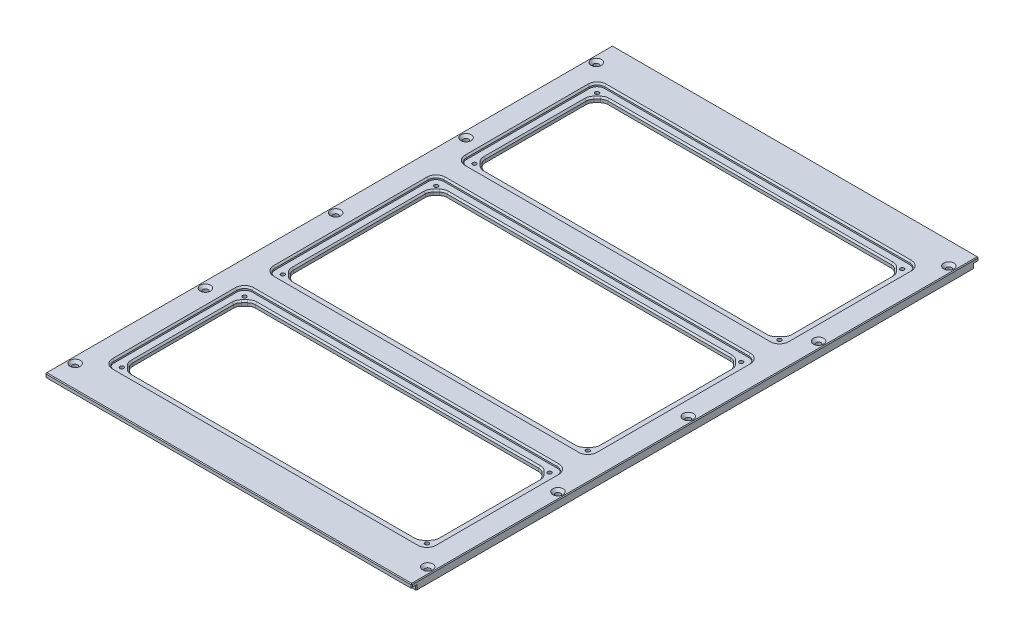
from build123d import *

# Parameters (mm, degrees)
SKETCH1_W                                            = 239
SKETCH1_H                                            = 370
BOSS_EXTRUDE1_DEPTH                                  = 5
CSK_FOR_M3_HEX_SOCKET_COUNTERSUNK_CAP_SC_D           = 3.4
CSK_FOR_M3_HEX_SOCKET_COUNTERSUNK_CAP_SC_CSINK_D     = 6.72
CSK_FOR_M3_HEX_SOCKET_COUNTERSUNK_CAP_SC_CSINK_ANGLE = 90
SKETCH4_W                                            = 209
SKETCH4_H                                            = 90
SKETCH4_H_2                                          = 110
CUT_EXTRUDE1_DEPTH                                   = 2
SKETCH5_W                                            = 199
SKETCH5_H                                            = 100
SKETCH5_H_2                                          = 80
CUT_EXTRUDE2_DEPTH                                   = 4
CHAMFER1_SIZE                                        = 5
FILLET1_R                                            = 5
CUT_EXTRUDE3_DEPTH                                   = 4
M3_TAPPED_HOLE1_AT_2_COUNT                           = 2
M3_TAPPED_HOLE1_AT_2_PITCH                           = 80
M3_TAPPED_HOLE1_AT_3_COUNT                           = 2
M3_TAPPED_HOLE1_AT_3_PITCH                           = 25
M3_TAPPED_HOLE1_AT_4_COUNT                           = 2
M3_TAPPED_HOLE1_AT_4_PITCH                           = 125
M3_TAPPED_HOLE1_AT_5_COUNT                           = 2
M3_TAPPED_HOLE1_AT_5_PITCH                           = 150
M3_TAPPED_HOLE1_AT_6_COUNT                           = 2
M3_TAPPED_HOLE1_AT_6_PITCH                           = 230
CHAMFER2_SIZE                                        = 1
SKETCH12_W                                           = 239
SKETCH12_H                                           = 3
CUT_EXTRUDE7_DEPTH                                   = 2.5
CHAMFER3_SIZE                                        = 0.5


with BuildPart() as part:
    # Sketch1 → Boss-Extrude1 (new body)
    with BuildSketch(Plane(origin=(0, 0, 0), x_dir=(1, 0, 0), z_dir=(0, 1, 0))):
        with Locations((-119.5, 185)):
            Rectangle(SKETCH1_W, SKETCH1_H)
    extrude(amount=BOSS_EXTRUDE1_DEPTH)

    # CSK for M3 Hex Socket Countersunk Cap Screw1 (through all)
    with Locations(Plane(origin=(0, 5, 0), x_dir=(1, 0, 0), z_dir=(0, 1, 0))):
        with Locations((-4.5, 15), (-4.5, 100), (-4.5, 185), (-4.5, 270), (-4.5, 355)):
            csk_for_m3_hex_socket_countersunk_cap_sc = CounterSinkHole(CSK_FOR_M3_HEX_SOCKET_COUNTERSUNK_CAP_SC_D / 2, CSK_FOR_M3_HEX_SOCKET_COUNTERSUNK_CAP_SC_CSINK_D / 2, counter_sink_angle=CSK_FOR_M3_HEX_SOCKET_COUNTERSUNK_CAP_SC_CSINK_ANGLE)

    # Sketch4 → Cut-Extrude1 (cut)
    with BuildSketch(Plane(origin=(0, 5, 0), x_dir=(1, 0, 0), z_dir=(0, 1, 0))):
        with Locations((-119.5, 300)):
            Rectangle(SKETCH4_W, SKETCH4_H)
        with Locations((-119.5, 185)):
            Rectangle(SKETCH4_W, SKETCH4_H_2)
        with Locations((-119.5, 70)):
            Rectangle(SKETCH4_W, SKETCH4_H)
    extrude(amount=-CUT_EXTRUDE1_DEPTH, mode=Mode.SUBTRACT)

    # Sketch5 → Cut-Extrude2 (cut, through all)
    with BuildSketch(Plane(origin=(0, 3, 0), x_dir=(1, 0, 0), z_dir=(0, 1, 0))):
        with Locations((-119.5, 185)):
            Rectangle(SKETCH5_W, SKETCH5_H)
        with Locations((-119.5, 70)):
            Rectangle(SKETCH5_W, SKETCH5_H_2)
        with Locations((-119.5, 300)):
            Rectangle(SKETCH5_W, SKETCH5_H_2)
    extrude(amount=-CUT_EXTRUDE2_DEPTH, mode=Mode.SUBTRACT)

    # Chamfer1
    chamfer1_edges = [part.edges().sort_by_distance(p)[0] for p in [
        (-219, 1.5, -30),
        (-219, 1.5, -110),
        (-20, 1.5, -260),
        (-219, 1.5, -260),
        (-219, 1.5, -340),
        (-20, 1.5, -340),
        (-20, 1.5, -235),
        (-20, 1.5, -135),
        (-219, 1.5, -135),
        (-219, 1.5, -235),
        (-20, 1.5, -110),
        (-20, 1.5, -30),
    ]]
    chamfer(chamfer1_edges, length=CHAMFER1_SIZE)

    # Fillet1
    fillet1_edges = [part.edges().sort_by_distance(p)[0] for p in [
        (-20, 1.5, -105),
        (-20, 1.5, -35),
        (-214, 1.5, -30),
        (-25, 1.5, -30),
        (-214, 1.5, -110),
        (-25, 1.5, -110),
        (-219, 1.5, -35),
        (-219, 1.5, -105),
        (-25, 1.5, -135),
        (-214, 1.5, -135),
        (-219, 1.5, -230),
        (-219, 1.5, -140),
        (-20, 1.5, -230),
        (-20, 1.5, -140),
        (-214, 1.5, -235),
        (-25, 1.5, -235),
        (-25, 1.5, -260),
        (-214, 1.5, -260),
        (-219, 1.5, -335),
        (-219, 1.5, -265),
        (-20, 1.5, -335),
        (-20, 1.5, -265),
        (-214, 1.5, -340),
        (-25, 1.5, -340),
        (-15, 4, -240),
        (-15, 4, -130),
        (-224, 4, -130),
        (-224, 4, -240),
        (-224, 4, -25),
        (-224, 4, -115),
        (-15, 4, -115),
        (-15, 4, -25),
        (-15, 4, -255),
        (-224, 4, -255),
        (-224, 4, -345),
        (-15, 4, -345),
    ]]
    fillet(fillet1_edges, radius=FILLET1_R)

    # Sketch6 → Cut-Extrude3 (cut)
    with BuildSketch(Plane.XZ):
        with BuildLine():
            Line((-224, -115.5), (-169, -115.5))
            ThreePointArc((-169, -115.5), (-162, -122.5), (-169, -129.5))
            Line((-169, -129.5), (-224, -129.5))
            ThreePointArc((-224, -129.5), (-231, -122.5), (-224, -115.5))
        make_face()
        with BuildLine():
            Line((-147, -115.5), (-92, -115.5))
            ThreePointArc((-92, -115.5), (-85, -122.5), (-92, -129.5))
            Line((-92, -129.5), (-147, -129.5))
            ThreePointArc((-147, -129.5), (-154, -122.5), (-147, -115.5))
        make_face()
        with BuildLine():
            Line((-70, -115.5), (-15, -115.5))
            ThreePointArc((-15, -115.5), (-8, -122.5), (-15, -129.5))
            Line((-15, -129.5), (-70, -129.5))
            ThreePointArc((-70, -129.5), (-77, -122.5), (-70, -115.5))
        make_face()
        with BuildLine():
            Line((-70, -254.5), (-15, -254.5))
            ThreePointArc((-15, -254.5), (-8, -247.5), (-15, -240.5))
            Line((-15, -240.5), (-70, -240.5))
            ThreePointArc((-70, -240.5), (-77, -247.5), (-70, -254.5))
        make_face()
        with BuildLine():
            Line((-147, -254.5), (-92, -254.5))
            ThreePointArc((-92, -254.5), (-85, -247.5), (-92, -240.5))
            Line((-92, -240.5), (-147, -240.5))
            ThreePointArc((-147, -240.5), (-154, -247.5), (-147, -254.5))
        make_face()
        with BuildLine():
            Line((-224, -254.5), (-169, -254.5))
            ThreePointArc((-169, -254.5), (-162, -247.5), (-169, -240.5))
            Line((-169, -240.5), (-224, -240.5))
            ThreePointArc((-224, -240.5), (-231, -247.5), (-224, -254.5))
        make_face()
        with BuildLine():
            Line((-196.798970952, -9.803274452), (-160.068481328, -23.803274452))
            ThreePointArc((-160.068481328, -23.803274452), (-157.297860755, -23.470368797), (-156, -21))
            Line((-156, -21), (-156, -7))
            ThreePointArc((-156, -7), (-156.878679656, -4.878679656), (-159, -4))
            Line((-159, -4), (-195.730489624, -4))
            ThreePointArc((-195.730489624, -4), (-198.680898355, -6.456779674), (-196.798970952, -9.803274452))
        make_face()
        with BuildLine():
            Line((-183.201029048, -18.196725548), (-219.931518672, -4.196725548))
            ThreePointArc((-219.931518672, -4.196725548), (-222.702139245, -4.529631203), (-224, -7))
            Line((-224, -7), (-224, -21))
            ThreePointArc((-224, -21), (-223.121320344, -23.121320344), (-221, -24))
            Line((-221, -24), (-184.269510376, -24))
            ThreePointArc((-184.269510376, -24), (-181.319101645, -21.543220326), (-183.201029048, -18.196725548))
        make_face()
        with BuildLine():
            Line((-151, -7), (-151, -21))
            ThreePointArc((-151, -21), (-149.664135543, -23.49612758), (-146.846231404, -23.769263084))
            Line((-146.846231404, -23.769263084), (-113.243580647, -9.769263084))
            ThreePointArc((-113.243580647, -9.769263084), (-111.455598977, -6.411692789), (-114.397349242, -4))
            Line((-114.397349242, -4), (-148, -4))
            ThreePointArc((-148, -4), (-150.121320344, -4.878679656), (-151, -7))
        make_face()
        with BuildLine():
            Line((-90.995776256, -24), (-124.598427014, -24))
            ThreePointArc((-124.598427014, -24), (-127.540177279, -21.588307211), (-125.752195609, -18.230736916))
            Line((-125.752195609, -18.230736916), (-92.149544852, -4.230736916))
            ThreePointArc((-92.149544852, -4.230736916), (-89.331640713, -4.50387242), (-87.995776256, -7))
            Line((-87.995776256, -7), (-87.995776256, -21))
            ThreePointArc((-87.995776256, -21), (-88.874455912, -23.121320344), (-90.995776256, -24))
        make_face()
        with BuildLine():
            Line((-79.995776256, -4), (-42.088822346, -4))
            ThreePointArc((-42.088822346, -4), (-39.135636887, -6.472083674), (-41.049465802, -9.814202902))
            Line((-41.049465802, -9.814202902), (-78.956419711, -23.814202902))
            ThreePointArc((-78.956419711, -23.814202902), (-81.710700506, -23.461510678), (-82.995776256, -21))
            Line((-82.995776256, -21), (-82.995776256, -7))
            ThreePointArc((-82.995776256, -7), (-82.117096599, -4.878679656), (-79.995776256, -4))
        make_face()
        with BuildLine():
            Line((-55.057521803, -18.185797098), (-17.150567893, -4.185797098))
            ThreePointArc((-17.150567893, -4.185797098), (-14.201891764, -4.686021019), (-13.150849099, -7.486061055))
            Line((-13.150849099, -7.486061055), (-15.449505209, -21.486061055))
            ThreePointArc((-15.449505209, -21.486061055), (-16.46798476, -23.286720705), (-18.409867459, -24))
            Line((-18.409867459, -24), (-54.018165259, -24))
            ThreePointArc((-54.018165259, -24), (-56.971350717, -21.527916326), (-55.057521803, -18.185797098))
        make_face()
        with BuildLine():
            Line((-13.150849099, -362.513938945), (-15.449505209, -348.513938945))
            ThreePointArc((-15.449505209, -348.513938945), (-16.46798476, -346.713279295), (-18.409867459, -346))
            Line((-18.409867459, -346), (-54.018165259, -346))
            ThreePointArc((-54.018165259, -346), (-56.971350717, -348.472083674), (-55.057521803, -351.814202902))
            Line((-55.057521803, -351.814202902), (-17.150567893, -365.814202902))
            ThreePointArc((-17.150567893, -365.814202902), (-14.201891764, -365.313978981), (-13.150849099, -362.513938945))
        make_face()
        with BuildLine():
            Line((-41.049465802, -360.185797098), (-78.956419711, -346.185797098))
            ThreePointArc((-78.956419711, -346.185797098), (-81.710700506, -346.538489322), (-82.995776256, -349))
            Line((-82.995776256, -349), (-82.995776256, -363))
            ThreePointArc((-82.995776256, -363), (-82.117096599, -365.121320344), (-79.995776256, -366))
            Line((-79.995776256, -366), (-42.088822346, -366))
            ThreePointArc((-42.088822346, -366), (-39.135636887, -363.527916326), (-41.049465802, -360.185797098))
        make_face()
        with BuildLine():
            Line((-87.995776256, -349), (-87.995776256, -363))
            ThreePointArc((-87.995776256, -363), (-89.331640713, -365.49612758), (-92.149544852, -365.769263084))
            Line((-92.149544852, -365.769263084), (-125.752195609, -351.769263084))
            ThreePointArc((-125.752195609, -351.769263084), (-127.540177279, -348.411692789), (-124.598427014, -346))
            Line((-124.598427014, -346), (-90.995776256, -346))
            ThreePointArc((-90.995776256, -346), (-88.874455912, -346.878679656), (-87.995776256, -349))
        make_face()
        with BuildLine():
            Line((-146.846231404, -346.230736916), (-113.243580647, -360.230736916))
            ThreePointArc((-113.243580647, -360.230736916), (-111.455598977, -363.588307211), (-114.397349242, -366))
            Line((-114.397349242, -366), (-148, -366))
            ThreePointArc((-148, -366), (-150.121320344, -365.121320344), (-151, -363))
            Line((-151, -363), (-151, -349))
            ThreePointArc((-151, -349), (-149.664135543, -346.50387242), (-146.846231404, -346.230736916))
        make_face()
        with BuildLine():
            Line((-224, -363), (-224, -349))
            ThreePointArc((-224, -349), (-223.121320344, -346.878679656), (-221, -346))
            Line((-221, -346), (-184.269510376, -346))
            ThreePointArc((-184.269510376, -346), (-181.319101645, -348.456779674), (-183.201029048, -351.803274452))
            Line((-183.201029048, -351.803274452), (-219.931518672, -365.803274452))
            ThreePointArc((-219.931518672, -365.803274452), (-222.702139245, -365.470368797), (-224, -363))
        make_face()
        with BuildLine():
            Line((-156, -349), (-156, -363))
            ThreePointArc((-156, -363), (-156.878679656, -365.121320344), (-159, -366))
            Line((-159, -366), (-195.730489624, -366))
            ThreePointArc((-195.730489624, -366), (-198.680898355, -363.543220326), (-196.798970952, -360.196725548))
            Line((-196.798970952, -360.196725548), (-160.068481328, -346.196725548))
            ThreePointArc((-160.068481328, -346.196725548), (-157.297860755, -346.529631203), (-156, -349))
        make_face()
    extrude(amount=-CUT_EXTRUDE3_DEPTH, mode=Mode.SUBTRACT)

    # Mirror1: CSK for M3 Hex Socket Countersunk Cap Screw1 across plane
    add(csk_for_m3_hex_socket_countersunk_cap_sc.mirror(Plane.ZY.offset(119.5)), mode=Mode.SUBTRACT)

    # Sketch9 → M3 Tapped Hole1 (revolve, cut)
    with BuildSketch(Plane(origin=(-219, 3, -110), x_dir=(0, 0, 1), z_dir=(1, 0, 0))):
        Polygon((0, 0), (0, 15.751075774), (1.25, 15), (1.25, 0), align=None)
    m3_tapped_hole1 = revolve(axis=Axis((-219, 9.35, -110), (0, -1, 0)), mode=Mode.SUBTRACT)

    # M3 Tapped Hole1 at 2: M3 Tapped Hole1 ×2
    with Locations(*[(0, 0, i * M3_TAPPED_HOLE1_AT_2_PITCH) for i in range(1, M3_TAPPED_HOLE1_AT_2_COUNT)]):
        add(m3_tapped_hole1, mode=Mode.SUBTRACT)

    # M3 Tapped Hole1 at 3: M3 Tapped Hole1 ×2
    with Locations(*[(0, 0, -i * M3_TAPPED_HOLE1_AT_3_PITCH) for i in range(1, M3_TAPPED_HOLE1_AT_3_COUNT)]):
        add(m3_tapped_hole1, mode=Mode.SUBTRACT)

    # M3 Tapped Hole1 at 4: M3 Tapped Hole1 ×2
    with Locations(*[(0, 0, -i * M3_TAPPED_HOLE1_AT_4_PITCH) for i in range(1, M3_TAPPED_HOLE1_AT_4_COUNT)]):
        add(m3_tapped_hole1, mode=Mode.SUBTRACT)

    # M3 Tapped Hole1 at 5: M3 Tapped Hole1 ×2
    with Locations(*[(0, 0, -i * M3_TAPPED_HOLE1_AT_5_PITCH) for i in range(1, M3_TAPPED_HOLE1_AT_5_COUNT)]):
        add(m3_tapped_hole1, mode=Mode.SUBTRACT)

    # M3 Tapped Hole1 at 6: M3 Tapped Hole1 ×2
    with Locations(*[(0, 0, -i * M3_TAPPED_HOLE1_AT_6_PITCH) for i in range(1, M3_TAPPED_HOLE1_AT_6_COUNT)]):
        add(m3_tapped_hole1, mode=Mode.SUBTRACT)

    # Mirror2: M3 Tapped Hole1 across plane
    add(m3_tapped_hole1.mirror(Plane.ZY.offset(119.5)), mode=Mode.SUBTRACT)

    # Mirror2 copy 1 sketch → Mirror2 copy 1 (revolve, cut)
    with BuildSketch(Plane(origin=(-20, 3, -30), x_dir=(0, 0, 1), z_dir=(-1, 0, 0))):
        Polygon((0, 0), (0, -15.751075774), (1.25, -15), (1.25, 0), align=None)
    revolve(axis=Axis((-20, 9.35, -30), (0, 1, 0)), mode=Mode.SUBTRACT)

    # Mirror2 copy 2 sketch → Mirror2 copy 2 (revolve, cut)
    with BuildSketch(Plane(origin=(-20, 3, -135), x_dir=(0, 0, 1), z_dir=(-1, 0, 0))):
        Polygon((0, 0), (0, -15.751075774), (1.25, -15), (1.25, 0), align=None)
    revolve(axis=Axis((-20, 9.35, -135), (0, 1, 0)), mode=Mode.SUBTRACT)

    # Mirror2 copy 3 sketch → Mirror2 copy 3 (revolve, cut)
    with BuildSketch(Plane(origin=(-20, 3, -235), x_dir=(0, 0, 1), z_dir=(-1, 0, 0))):
        Polygon((0, 0), (0, -15.751075774), (1.25, -15), (1.25, 0), align=None)
    revolve(axis=Axis((-20, 9.35, -235), (0, 1, 0)), mode=Mode.SUBTRACT)

    # Mirror2 copy 4 sketch → Mirror2 copy 4 (revolve, cut)
    with BuildSketch(Plane(origin=(-20, 3, -260), x_dir=(0, 0, 1), z_dir=(-1, 0, 0))):
        Polygon((0, 0), (0, -15.751075774), (1.25, -15), (1.25, 0), align=None)
    revolve(axis=Axis((-20, 9.35, -260), (0, 1, 0)), mode=Mode.SUBTRACT)

    # Mirror2 copy 5 sketch → Mirror2 copy 5 (revolve, cut)
    with BuildSketch(Plane(origin=(-20, 3, -340), x_dir=(0, 0, 1), z_dir=(-1, 0, 0))):
        Polygon((0, 0), (0, -15.751075774), (1.25, -15), (1.25, 0), align=None)
    revolve(axis=Axis((-20, 9.35, -340), (0, 1, 0)), mode=Mode.SUBTRACT)

    # Chamfer2
    chamfer2_edges = [part.edges().sort_by_distance(p)[0] for p in [
        (-119.5, 3, -135),
        (-22.5, 3, -137.5),
        (-20, 3, -185),
        (-119.5, 3, -340),
        (-22.5, 3, -337.5),
        (-20, 3, -300),
        (-219, 3, -185),
        (-216.5, 3, -232.5),
        (-119.5, 3, -235),
        (-216.5, 3, -337.5),
        (-219, 3, -300),
        (-119.5, 3, -260),
        (-216.5, 3, -262.5),
        (-216.5, 3, -137.5),
        (-22.5, 3, -262.5),
        (-22.5, 3, -232.5),
        (-20, 3, -70),
        (-22.5, 3, -107.5),
        (-119.5, 3, -110),
        (-216.5, 3, -107.5),
        (-219, 3, -70),
        (-216.5, 3, -32.5),
        (-119.5, 3, -30),
        (-22.5, 3, -32.5),
        (-119.5, 5, -115),
        (-15, 5, -70),
        (-224, 5, -70),
        (-119.5, 5, -25),
        (-15, 5, -185),
        (-119.5, 5, -130),
        (-224, 5, -185),
        (-119.5, 5, -240),
        (-15, 5, -300),
        (-119.5, 5, -255),
        (-224, 5, -300),
        (-119.5, 5, -345),
        (-25.15765065, 3, -135.380602337),
        (-20.380602337, 3, -140.15765065),
        (-25.15765065, 3, -339.619397663),
        (-20.380602337, 3, -334.84234935),
        (-218.619397663, 3, -229.84234935),
        (-213.84234935, 3, -234.619397663),
        (-213.84234935, 3, -339.619397663),
        (-218.619397663, 3, -334.84234935),
        (-213.84234935, 3, -260.380602337),
        (-218.619397663, 3, -265.15765065),
        (-213.84234935, 3, -135.380602337),
        (-218.619397663, 3, -140.15765065),
        (-25.15765065, 3, -260.380602337),
        (-20.380602337, 3, -265.15765065),
        (-25.15765065, 3, -234.619397663),
        (-20.380602337, 3, -229.84234935),
        (-20.380602337, 3, -104.84234935),
        (-25.15765065, 3, -109.619397663),
        (-213.84234935, 3, -109.619397663),
        (-218.619397663, 3, -104.84234935),
        (-218.619397663, 3, -35.15765065),
        (-213.84234935, 3, -30.380602337),
        (-20.380602337, 3, -35.15765065),
        (-25.15765065, 3, -30.380602337),
        (-16.464466094, 5, -113.535533906),
        (-222.535533906, 5, -113.535533906),
        (-222.535533906, 5, -26.464466094),
        (-16.464466094, 5, -26.464466094),
        (-16.464466094, 5, -131.464466094),
        (-222.535533906, 5, -131.464466094),
        (-222.535533906, 5, -238.535533906),
        (-16.464466094, 5, -238.535533906),
        (-16.464466094, 5, -256.464466094),
        (-222.535533906, 5, -256.464466094),
        (-222.535533906, 5, -343.535533906),
        (-16.464466094, 5, -343.535533906),
    ]]
    chamfer(chamfer2_edges, length=CHAMFER2_SIZE)

    # Sketch12 → Cut-Extrude7 (cut)
    with BuildSketch(Plane.XZ):
        with Locations((-119.5, -1.5)):
            Rectangle(SKETCH12_W, SKETCH12_H)
        with Locations((-119.5, -368.5)):
            Rectangle(SKETCH12_W, SKETCH12_H)
    extrude(amount=-CUT_EXTRUDE7_DEPTH, mode=Mode.SUBTRACT)

    # Chamfer3
    chamfer3_edges = [part.edges().sort_by_distance(p)[0] for p in [
        (-239, 5, -185),
        (0, 2.5, -1.5),
        (0, 1.25, -3),
        (-239, 2.5, -1.5),
        (-239, 1.25, -3),
        (-239, 2.5, -368.5),
        (-239, 1.25, -367),
        (0, 2.5, -368.5),
        (0, 1.25, -367),
        (-119.5, 5, 0),
        (0, 5, -185),
        (-119.5, 5, -370),
        (0, 3.75, 0),
        (-239, 3.75, 0),
        (-239, 3.75, -370),
        (0, 3.75, -370),
    ]]
    chamfer(chamfer3_edges, length=CHAMFER3_SIZE)


solid = part.part
